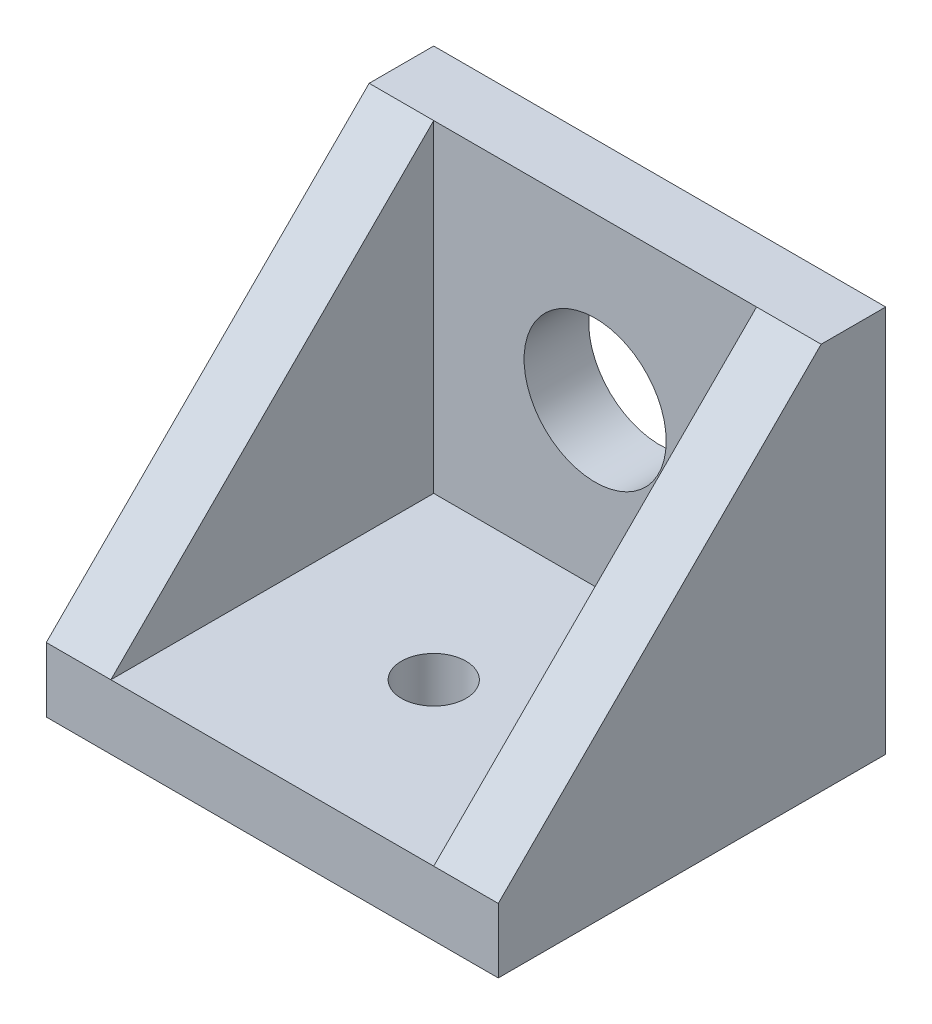
from build123d import *

# Parameters (mm, degrees)
SKETCH1_W           = 15
SKETCH1_H           = 15
SKETCH1_R           = 3.302
BOSS_EXTRUDE1_DEPTH = 3
SKETCH2_W           = 15
SKETCH2_H           = 18
SKETCH2_R           = 1.5
BOSS_EXTRUDE2_DEPTH = 3
BOSS_EXTRUDE3_DEPTH = 3


with BuildPart() as part:
    # Sketch1 → Boss-Extrude1 (new body)
    with BuildSketch(Plane.XY):
        Rectangle(SKETCH1_W, SKETCH1_H)
        Circle(SKETCH1_R, mode=Mode.SUBTRACT)
    extrude(amount=BOSS_EXTRUDE1_DEPTH)

    # Sketch2 → Boss-Extrude2 (add)
    with BuildSketch(Plane.XZ.offset(7.5)):
        with Locations((0, 9)):
            Rectangle(SKETCH2_W, SKETCH2_H)
        with Locations((0, 10.5)):
            Circle(SKETCH2_R, mode=Mode.SUBTRACT)
    extrude(amount=BOSS_EXTRUDE2_DEPTH)

    # Sketch3 → Boss-Extrude3 (add)
    with BuildSketch(Plane(origin=(7.5, 0, 0), x_dir=(0, 0, -1), z_dir=(1, 0, 0))):
        Polygon((-18, -10.5), (-18, -7.5), (-3, 7.5), (0, 7.5), (0, -10.5), align=None)
    boss_extrude3 = extrude(amount=BOSS_EXTRUDE3_DEPTH)

    # Mirror1: Boss-Extrude3 across plane
    add(boss_extrude3.mirror(Plane(origin=(0, 0, 0), x_dir=(0, 0, 1), z_dir=(1, 0, 0))))


solid = part.part
